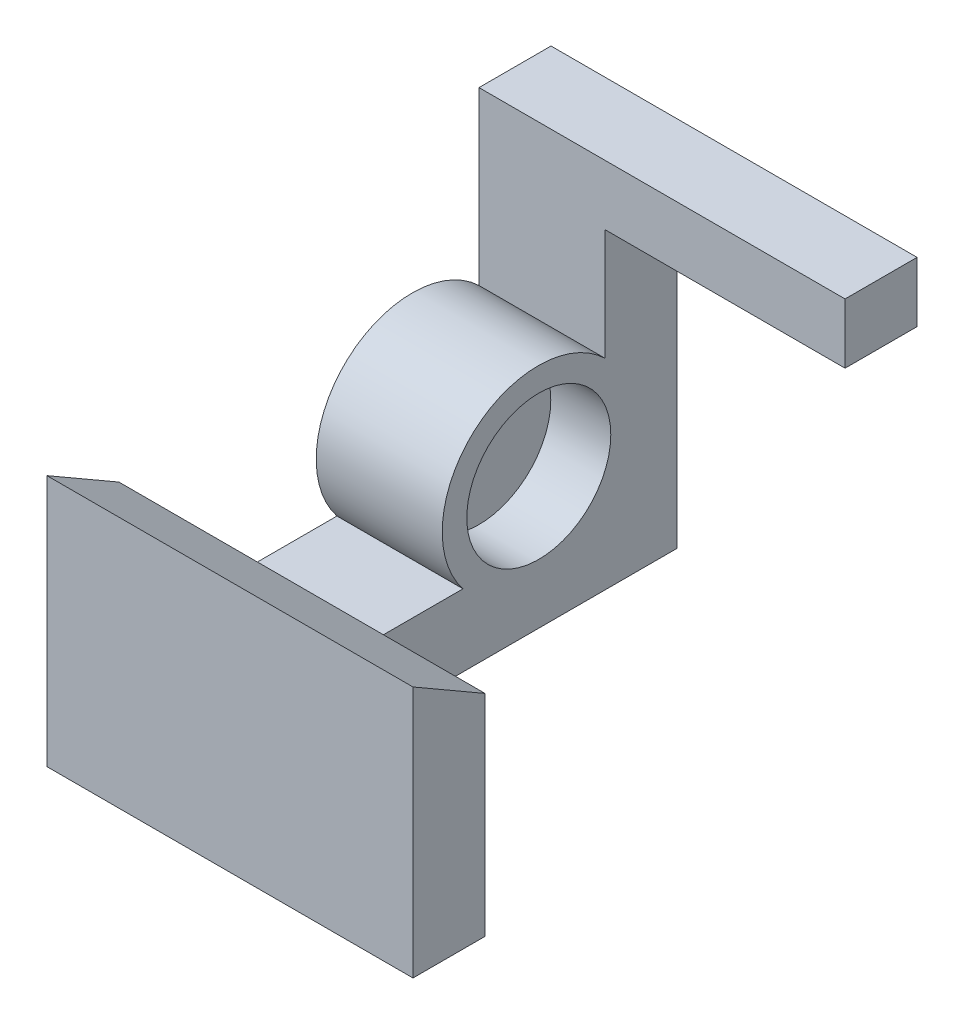
from build123d import *

# Parameters (mm, degrees)
BOSS_EXTRUDE1_DEPTH = 10.5
SKETCH4_W           = 30.5
SKETCH4_H           = 6
BOSS_EXTRUDE2_DEPTH = 5
SKETCH5_W           = 30.5
SKETCH5_H           = 6
BOSS_EXTRUDE3_DEPTH = 6
SKETCH6_R           = 6
CUT_EXTRUDE2_DEPTH  = 5
SKETCH11_W          = 30.5
SKETCH11_H          = 6
BOSS_EXTRUDE5_DEPTH = 15
CUT_EXTRUDE4_DEPTH  = 31.5


with BuildPart() as part:
    # Sketch2 → Boss-Extrude1 (new body)
    with BuildSketch(Plane(origin=(0, 0, 0), x_dir=(0, 0, -1), z_dir=(1, 0, 0))):
        with BuildLine():
            Line((2.711841856, 20.960264901), (-3.288158144, 20.960264901))
            Line((-3.288158144, 20.960264901), (-3.288158144, 11.676412171))
            ThreePointArc((-3.288158144, 11.676412171), (-14.220841983, 11.857208885), (-15.122437882, 0.960264901))
            Line((-15.122437882, 0.960264901), (-33.288158144, 0.960264901))
            Line((-33.288158144, 0.960264901), (-33.288158144, -5.039735099))
            Line((-33.288158144, -5.039735099), (2.711841856, -5.039735099))
            Line((2.711841856, -5.039735099), (2.711841856, 20.960264901))
        make_face()
    extrude(amount=-BOSS_EXTRUDE1_DEPTH)

    # Sketch4 → Boss-Extrude2 (add)
    with BuildSketch(Plane(origin=(0, 20.960264901, 0), x_dir=(1, 0, 0), z_dir=(0, 1, 0))):
        with Locations((4.75, -0.288158144)):
            Rectangle(SKETCH4_W, SKETCH4_H)
    extrude(amount=BOSS_EXTRUDE2_DEPTH)

    # Sketch5 → Boss-Extrude3 (add)
    with BuildSketch(Plane.XY.offset(33.288158144)):
        with Locations((4.75, -2.039735099)):
            Rectangle(SKETCH5_W, SKETCH5_H)
    extrude(amount=BOSS_EXTRUDE3_DEPTH)

    # Sketch6 → Cut-Extrude2 (cut)
    with BuildSketch(Plane(origin=(0, 0, 0), x_dir=(0, 0, -1), z_dir=(1, 0, 0))):
        with Locations((-8.806939463, 5.923867659)):
            Circle(SKETCH6_R)
    extrude(amount=-CUT_EXTRUDE2_DEPTH, mode=Mode.SUBTRACT)

    # Sketch11 → Boss-Extrude5 (add)
    with BuildSketch(Plane(origin=(0, 0.960264901, 0), x_dir=(1, 0, 0), z_dir=(0, 1, 0))):
        with Locations((4.75, -36.288158144)):
            Rectangle(SKETCH11_W, SKETCH11_H)
    extrude(amount=BOSS_EXTRUDE5_DEPTH)

    # Sketch12 → Cut-Extrude4 (cut, through all)
    with BuildSketch(Plane.ZY.offset(10.5)):
        Polygon((33.288158144, 15.960264901), (39.288158144, 15.960264901), (33.288158144, 12.496163286), align=None)
    extrude(amount=-CUT_EXTRUDE4_DEPTH, mode=Mode.SUBTRACT)


solid = part.part
